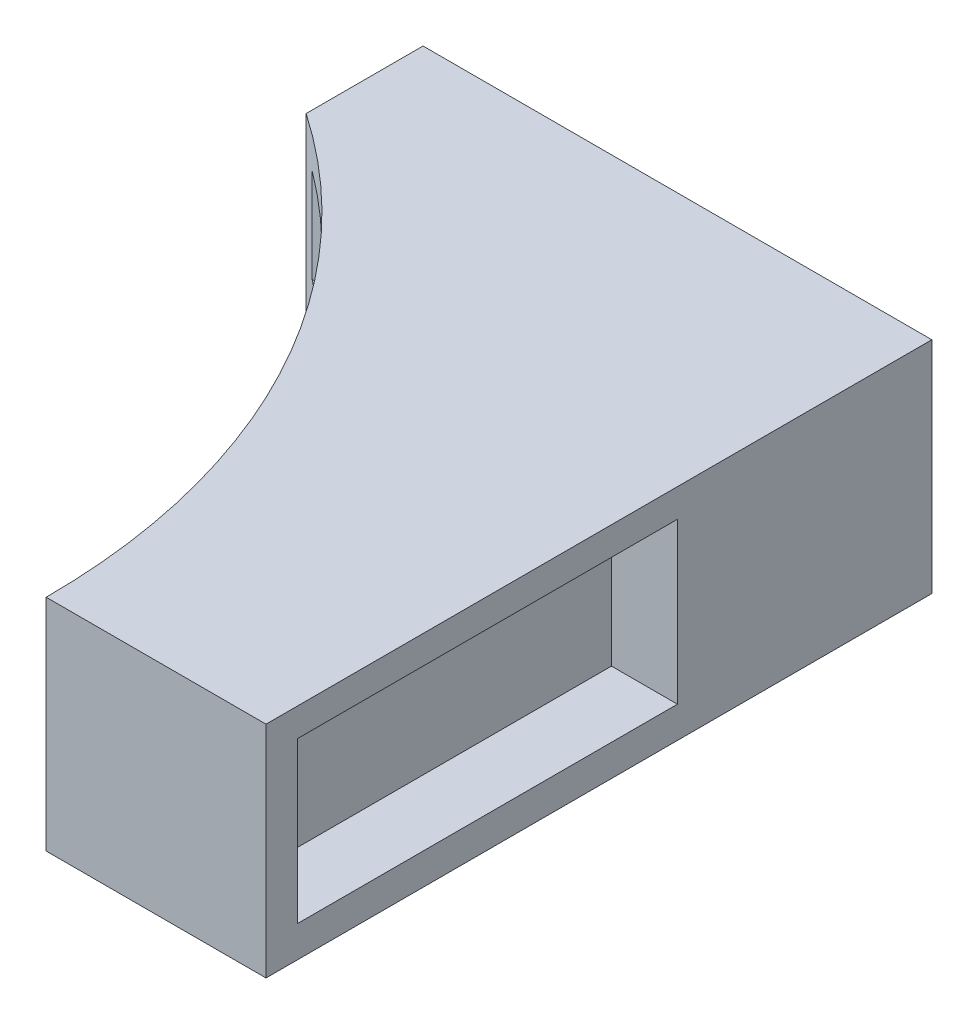
from build123d import *

# Parameters (mm, degrees)
BOSS_EXTRUDE1_DEPTH = 7
CUT_EXTRUDE1_DEPTH  = 8
SKETCH5_W           = 15
SKETCH5_H           = 3
CUT_EXTRUDE3_DEPTH  = 10
SKETCH6_W           = 12.1
SKETCH6_H           = 5.1
CUT_EXTRUDE4_DEPTH  = 2.1


with BuildPart() as part:
    # Sketch1 → Boss-Extrude1 (new body)
    with BuildSketch(Plane(origin=(0, 0, 0), x_dir=(1, 0, 0), z_dir=(0, 1, 0))):
        with BuildLine():
            Line((7, 21.2), (-21.2, 21.2))
            ThreePointArc((-21.2, 21.2), (-6.209336239, 14.990663761), (0, 0))
            Line((0, 0), (7, 0))
            Line((7, 0), (7, 21.2))
        make_face()
    extrude(amount=BOSS_EXTRUDE1_DEPTH)

    # Sketch2 → Cut-Extrude1 (cut, through all)
    with BuildSketch(Plane(origin=(0, 7, 0), x_dir=(1, 0, 0), z_dir=(0, 1, 0))):
        with BuildLine():
            Line((-9.2, 17.47684182), (-9.2, 21.2))
            Line((-9.2, 21.2), (-21.2, 21.2))
            ThreePointArc((-21.2, 21.2), (-14.917844581, 20.247827619), (-9.2, 17.47684182))
        make_face()
    extrude(amount=-CUT_EXTRUDE1_DEPTH, mode=Mode.SUBTRACT)

    # Sketch5 → Cut-Extrude3 (cut)
    with BuildSketch(Plane(origin=(0, 0, 0), x_dir=(0, 0, -1), z_dir=(1, 0, 0))):
        with Locations((9.5, 4.5)):
            Rectangle(SKETCH5_W, SKETCH5_H)
    extrude(amount=-CUT_EXTRUDE3_DEPTH, mode=Mode.SUBTRACT)

    # Sketch6 → Cut-Extrude4 (cut)
    with BuildSketch(Plane(origin=(7, 0, 0), x_dir=(0, 0, -1), z_dir=(1, 0, 0))):
        with Locations((7.05, 3.55)):
            Rectangle(SKETCH6_W, SKETCH6_H)
    extrude(amount=-CUT_EXTRUDE4_DEPTH, mode=Mode.SUBTRACT)


solid = part.part
